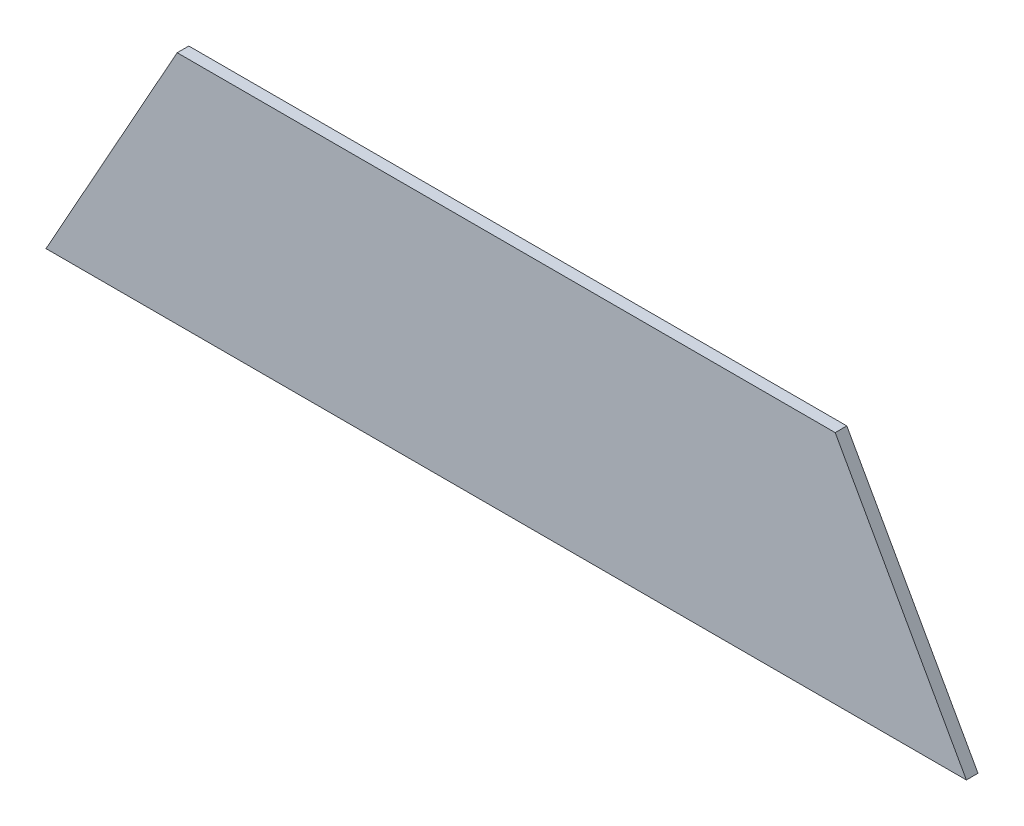
from build123d import *

# Parameters (mm, degrees)
BOSS_EXTRUDE1_DEPTH = 11.90625


with BuildPart() as part:
    # Sketch1 → Boss-Extrude1 (new body)
    with BuildSketch(Plane.XY):
        Polygon((-471.550272559, -687.09300222), (-337.114930678, -446.030141975), (337.114930678, -446.030141975), (471.550272559, -687.09300222), align=None)
    extrude(amount=-BOSS_EXTRUDE1_DEPTH)


solid = part.part
